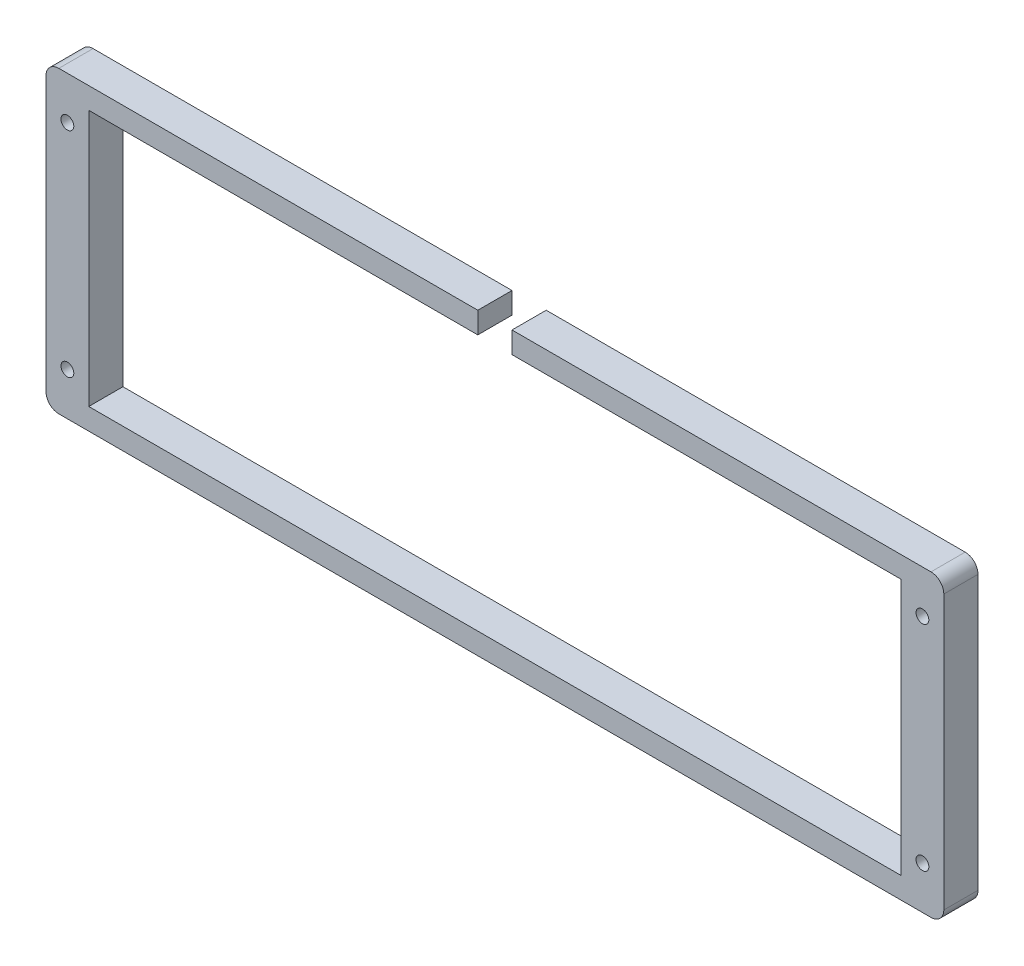
from build123d import *

# Parameters (mm, degrees)
SKETCH_1_W          = 210
SKETCH_1_H          = 70
EXTRUDE_1_DEPTH     = 8
SKETCH_2_W          = 190
SKETCH_2_H          = 60
CUT_EXTRUDE_1_DEPTH = 10
SKETCH_3_R          = 1.5
CUT_EXTRUDE_2_DEPTH = 10
SKETCH_4_W          = 8
SKETCH_4_H          = 10
CUT_EXTRUDE_3_DEPTH = 5
FILLET_1_R          = 3


with BuildPart() as part:
    # 草图1 → 凸台-拉伸1 (new body)
    with BuildSketch(Plane.XY):
        with Locations((75, 11.5)):
            Rectangle(SKETCH_1_W, SKETCH_1_H)
    extrude(amount=EXTRUDE_1_DEPTH)

    # 草图2 → 切除-拉伸1 (cut)
    with BuildSketch(Plane.XY):
        with Locations((75, 11.5)):
            Rectangle(SKETCH_2_W, SKETCH_2_H)
    extrude(amount=CUT_EXTRUDE_1_DEPTH, mode=Mode.SUBTRACT)

    # 草图3 → 切除-拉伸2 (cut)
    with BuildSketch(Plane.XY):
        with Locations((-25, 36.5)):
            Circle(SKETCH_3_R)
        with Locations((175, 36.5)):
            Circle(SKETCH_3_R)
        with Locations((-25, -13.5)):
            Circle(SKETCH_3_R)
        with Locations((175, -13.5)):
            Circle(SKETCH_3_R)
    extrude(amount=CUT_EXTRUDE_2_DEPTH, mode=Mode.SUBTRACT)

    # 草图4 → 切除-拉伸3 (cut)
    with BuildSketch(Plane(origin=(0, 46.5, 0), x_dir=(1, 0, 0), z_dir=(0, 1, 0))):
        with Locations((75, -5)):
            Rectangle(SKETCH_4_W, SKETCH_4_H)
    extrude(amount=-CUT_EXTRUDE_3_DEPTH, mode=Mode.SUBTRACT)

    # 圆角1
    fillet_1_edges = [part.edges().sort_by_distance(p)[0] for p in [
        (-30, 46.5, 4),
        (180, 46.5, 4),
        (180, -23.5, 4),
        (-30, -23.5, 4),
    ]]
    fillet(fillet_1_edges, radius=FILLET_1_R)


solid = part.part
